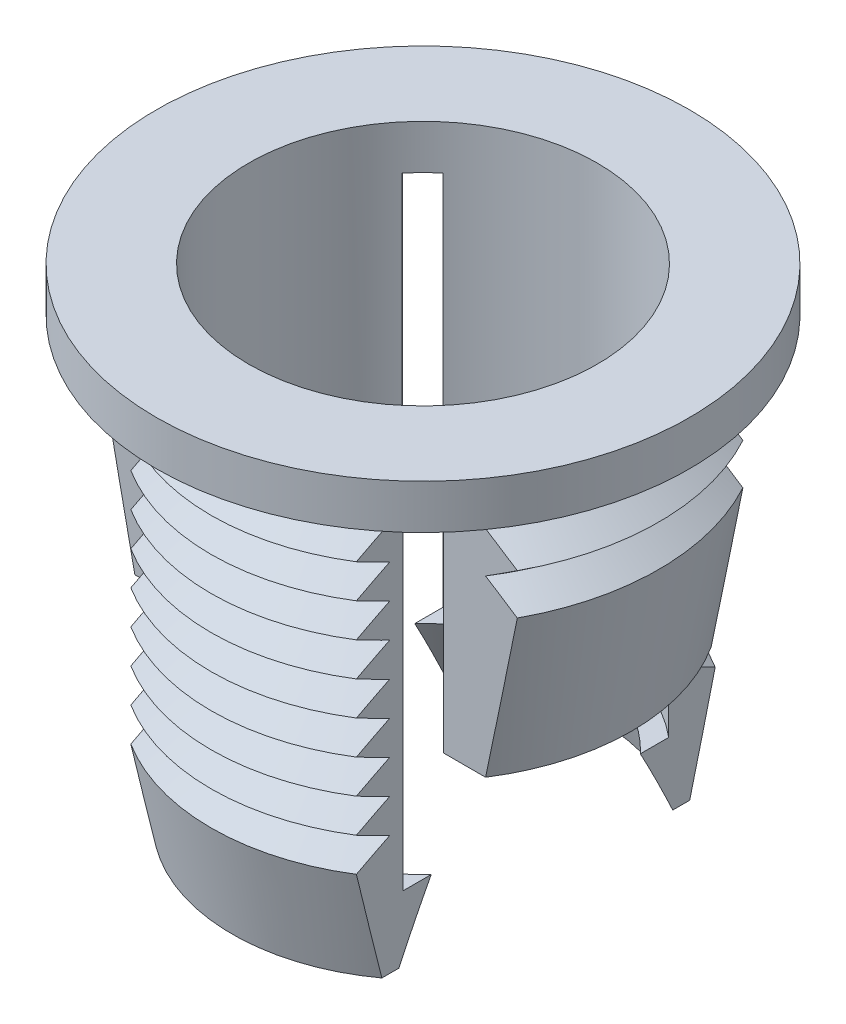
from build123d import *

# Parameters (mm, degrees)
SKETCH1_R               = 3.9
SKETCH1_R_2             = 2.55
BOSS_EXTRUDE1_DEPTH     = 0.65
SKETCH3_W               = 3.9
SKETCH3_H               = 6
CUT_EXTRUDE1_DEPTH      = 4.9
CUT_EXTRUDE1_DEPTH_BACK = 4.9
SKETCH4_W               = 3
SKETCH4_H               = 9
CUT_EXTRUDE2_DEPTH      = 4.9
CUT_EXTRUDE2_DEPTH_BACK = 4.9
SKETCH6_R               = 2.55
CUT_EXTRUDE3_DEPTH      = 5.5
SKETCH7_W               = 4
SKETCH7_H               = 8
CUT_EXTRUDE5_DEPTH      = 4.9
CUT_EXTRUDE5_DEPTH_BACK = 4.9
SKETCH9_R               = 2.25
CUT_EXTRUDE6_DEPTH      = 5.5
CUT_EXTRUDE6_TAPER      = -20


with BuildPart() as part:
    # Sketch1 → Boss-Extrude1 (new body)
    with BuildSketch(Plane(origin=(0, 0, 0), x_dir=(1, 0, 0), z_dir=(0, 1, 0))):
        Circle(SKETCH1_R)
        Circle(SKETCH1_R_2, mode=Mode.SUBTRACT)
    extrude(amount=BOSS_EXTRUDE1_DEPTH)

    # Sketch2 → Revolve1 (revolve)
    with BuildSketch(Plane.XY):
        Polygon((-2.55, 0), (-3.05, 0), (-3.45, -0.3), (-3.05, -0.6), (-3.45, -0.9), (-3.05, -1.2), (-3.45, -1.5), (-3.05, -3.75), (-2.55, -3.75), align=None)
    revolve(axis=Axis((0, 0, 0), (0, -1, 0)))

    # Sketch3 → Cut-Extrude1 (cut, two sides)
    with BuildSketch(Plane.XY) as cut_extrude1_sk:
        with Locations((0, -3)):
            Rectangle(SKETCH3_W, SKETCH3_H)
    extrude(amount=CUT_EXTRUDE1_DEPTH, mode=Mode.SUBTRACT)
    extrude(cut_extrude1_sk.sketch, amount=-CUT_EXTRUDE1_DEPTH_BACK, mode=Mode.SUBTRACT)

    # Sketch4 → Cut-Extrude2 (cut, two sides)
    with BuildSketch(Plane(origin=(0, 0, 0), x_dir=(0, 0, -1), z_dir=(1, 0, 0))) as cut_extrude2_sk:
        with Locations((-3.15, -4.5)):
            Rectangle(SKETCH4_W, SKETCH4_H)
        with Locations((3.15, -4.5)):
            Rectangle(SKETCH4_W, SKETCH4_H)
    extrude(amount=CUT_EXTRUDE2_DEPTH, mode=Mode.SUBTRACT)
    extrude(cut_extrude2_sk.sketch, amount=-CUT_EXTRUDE2_DEPTH_BACK, mode=Mode.SUBTRACT)


with BuildPart() as body_2:
    # Sketch5 → Revolve2 (revolve)
    with BuildSketch(Plane(origin=(0, 0, 0), x_dir=(0, 0, -1), z_dir=(1, 0, 0))):
        Polygon((3.1, -4.95), (2.7, -4.7025), (3.1, -4.455), (2.7, -4.2075), (3.1, -3.96), (2.7, -3.7125), (3.1, -3.465), (2.7, -3.2175), (3.1, -2.97), (2.7, -2.7225), (3.1, -2.475), (2.7, -2.2275), (3.1, -1.98), (2.7, -1.7325), (3.1, -1.485), (2.7, -1.2375), (3.1, -0.99), (2.7, -0.7425), (3.1, -0.495), (2.7, -0.2475), (3.1, 0), (0, 0), (0, -6.45), (2.791521213, -6.45), align=None)
    revolve(axis=Axis((0, 0, 0), (0, -1, 0)))

    # Sketch6 → Cut-Extrude3 (cut)
    with BuildSketch(Plane(origin=(0, 0, 0), x_dir=(1, 0, 0), z_dir=(0, 1, 0))):
        Circle(SKETCH6_R)
    extrude(amount=-CUT_EXTRUDE3_DEPTH, mode=Mode.SUBTRACT)

    # Sketch7 → Cut-Extrude5 (cut, two sides)
    with BuildSketch(Plane.XY) as cut_extrude5_sk:
        with Locations((3.65, -4)):
            Rectangle(SKETCH7_W, SKETCH7_H)
        with Locations((-3.65, -4)):
            Rectangle(SKETCH7_W, SKETCH7_H)
    extrude(amount=CUT_EXTRUDE5_DEPTH, mode=Mode.SUBTRACT)
    extrude(cut_extrude5_sk.sketch, amount=-CUT_EXTRUDE5_DEPTH_BACK, mode=Mode.SUBTRACT)

    # Sketch9 → Cut-Extrude6 (cut)
    with BuildSketch(Plane(origin=(0, -5.5, 0), x_dir=(1, 0, 0), z_dir=(0, 1, 0))):
        Circle(SKETCH9_R)
    extrude(amount=-CUT_EXTRUDE6_DEPTH, taper=CUT_EXTRUDE6_TAPER, mode=Mode.SUBTRACT)


with BuildPart() as part_1:
    add(part.part)

    # Combine1: union body 2
    add(body_2.part)


solid = part_1.part
